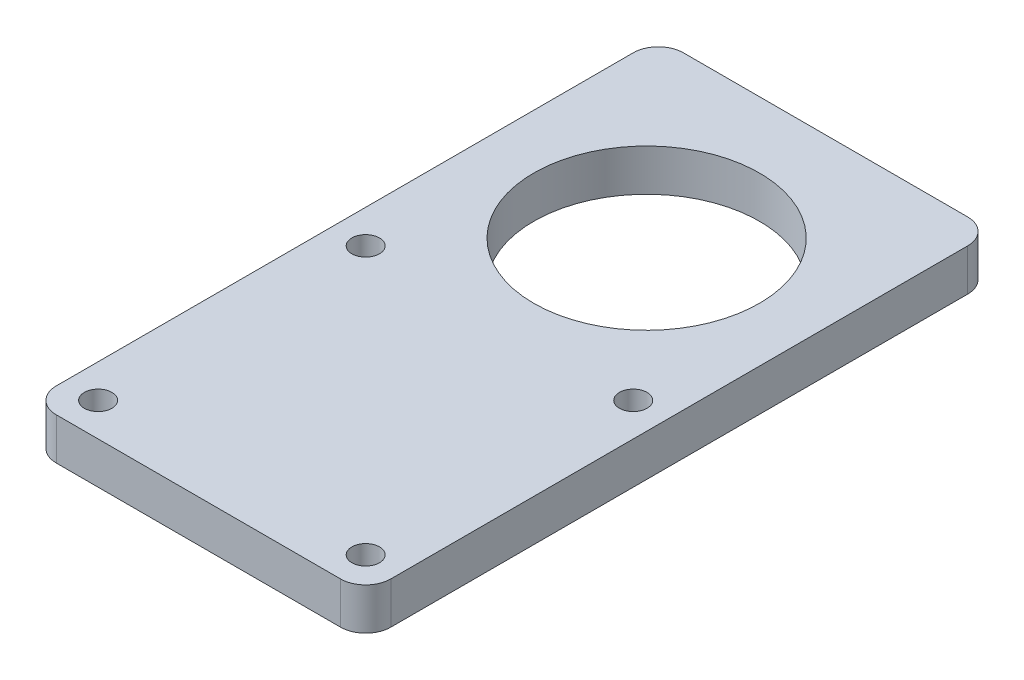
from build123d import *

# Parameters (mm, degrees)
SKETCH_1_W      = 40
SKETCH_1_H      = 75
SKETCH_1_R      = 1.65
SKETCH_1_R_2    = 13.5
EXTRUDE_1_DEPTH = 5
FILLET_1_R      = 3


with BuildPart() as part:
    # 草图1 → 凸台-拉伸1 (new body)
    with BuildSketch(Plane(origin=(0, 0, 0), x_dir=(1, 0, 0), z_dir=(0, 1, 0))):
        with Locations((0, 17.5)):
            Rectangle(SKETCH_1_W, SKETCH_1_H)
        with Locations((-16, 16)):
            Circle(SKETCH_1_R, mode=Mode.SUBTRACT)
        with Locations((16, 16)):
            Circle(SKETCH_1_R, mode=Mode.SUBTRACT)
        with Locations((16, -16)):
            Circle(SKETCH_1_R, mode=Mode.SUBTRACT)
        with Locations((-16, -16)):
            Circle(SKETCH_1_R, mode=Mode.SUBTRACT)
        with Locations((0, 33.6)):
            Circle(SKETCH_1_R_2, mode=Mode.SUBTRACT)
    extrude(amount=EXTRUDE_1_DEPTH)

    # 圆角1
    fillet_1_edges = [part.edges().sort_by_distance(p)[0] for p in [
        (20, 2.5, 20),
        (-20, 2.5, 20),
        (-20, 2.5, -55),
        (20, 2.5, -55),
    ]]
    fillet(fillet_1_edges, radius=FILLET_1_R)


solid = part.part
